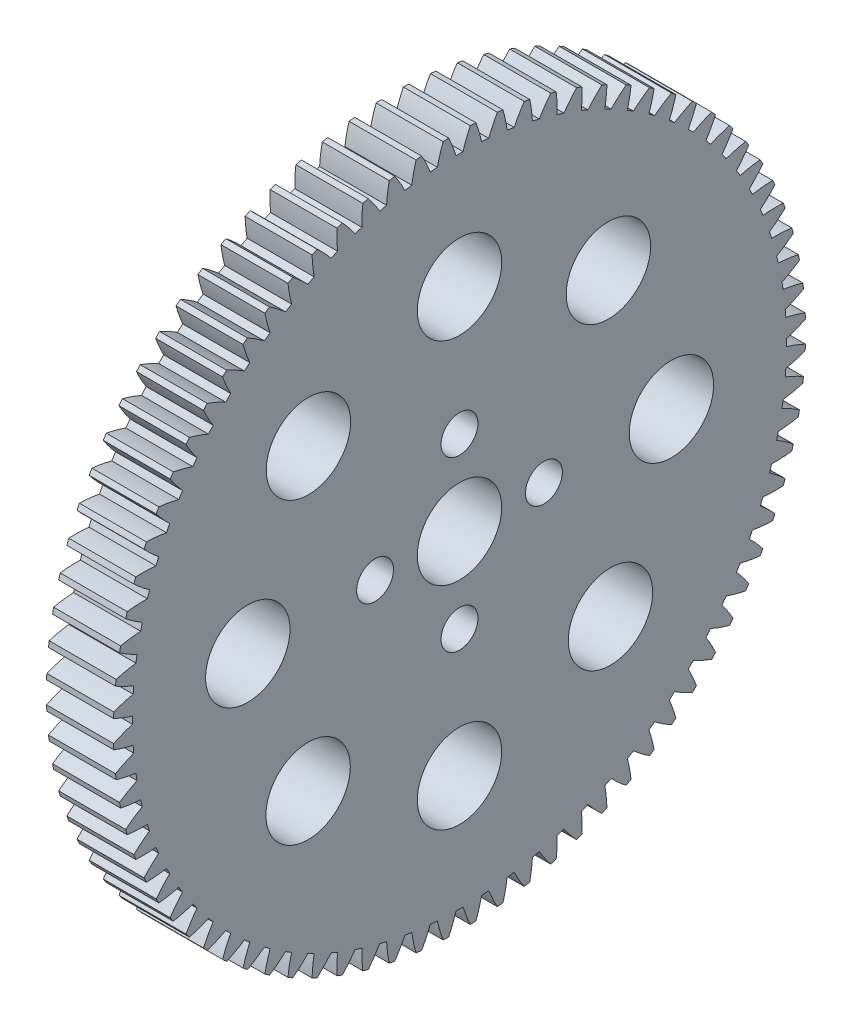
from build123d import *

# Parameters (mm, degrees)
SKETCH1_R           = 4
SKETCH1_R_2         = 1.75
BOSS_EXTRUDE1_DEPTH = 3.175


with BuildPart() as part:
    # Sketch1 → Boss-Extrude1 (new, symmetric)
    with BuildSketch(Plane(origin=(0, 0, 0), x_dir=(0, -1, 0), z_dir=(-1, 0, 0))):
        with BuildLine():
            ThreePointArc((-32.540485036, -4.117867604), (-31.611759802, -4.35271874), (-30.668071435, -4.517454533))
            ThreePointArc((-30.668071435, -4.517454533), (-30.61735087, -4.849311982), (-30.563039402, -5.180600688))
            ThreePointArc((-30.563039402, -5.180600688), (-31.409634214, -5.62888948), (-32.220331407, -6.139238063))
            ThreePointArc((-32.220331407, -6.139238063), (-32.169757197, -6.398962562), (-32.117089412, -6.658270623))
            ThreePointArc((-32.117089412, -6.658270623), (-31.17280092, -6.819530849), (-30.219096608, -6.909717881))
            ThreePointArc((-30.219096608, -6.909717881), (-30.142495162, -7.236572834), (-30.062358507, -7.562579059))
            ThreePointArc((-30.062358507, -7.562579059), (-30.871171216, -8.075908989), (-31.639327812, -8.648290907))
            ThreePointArc((-31.639327812, -8.648290907), (-31.568531756, -8.903246756), (-31.495681252, -9.15762319))
            ThreePointArc((-31.495681252, -9.15762319), (-30.541651355, -9.244298283), (-29.583811002, -9.25938052))
            ThreePointArc((-29.583811002, -9.25938052), (-29.481800949, -9.579217809), (-29.376333174, -9.897931615))
            ThreePointArc((-29.376333174, -9.897931615), (-30.142377181, -10.473137835), (-30.863257239, -11.104024162))
            ThreePointArc((-30.863257239, -11.104024162), (-30.772675818, -11.352639472), (-30.680091743, -11.600515964))
            ThreePointArc((-30.680091743, -11.600515964), (-29.722202353, -11.612071544), (-28.766131363, -11.551955999))
            ThreePointArc((-28.766131363, -11.551955999), (-28.639341628, -11.86280372), (-28.509192978, -12.172260132))
            ThreePointArc((-28.509192978, -12.172260132), (-29.227745368, -12.805796303), (-29.896904422, -13.491297415))
            ThreePointArc((-29.896904422, -13.491297415), (-29.787096101, -13.732039391), (-29.675349267, -13.9718877))
            ThreePointArc((-29.675349267, -13.9718877), (-28.719506089, -13.908252522), (-27.771098959, -13.773309829))
            ThreePointArc((-27.771098959, -13.773309829), (-27.620311243, -14.073251501), (-27.466284128, -14.371542617))
            ThreePointArc((-27.466284128, -14.371542617), (-28.132914785, -15.059502778), (-28.746227248, -15.795392334))
            ThreePointArc((-28.746227248, -15.795392334), (-28.617869032, -16.026776721), (-28.487648394, -16.257118102))
            ThreePointArc((-28.487648394, -16.257118102), (-27.53974452, -16.118684499), (-26.604848494, -15.909746623))
            ThreePointArc((-26.604848494, -15.909746623), (-26.430992455, -16.196933008), (-26.254036502, -16.482219763))
            ThreePointArc((-26.254036502, -16.482219763), (-26.864635428, -17.220362411), (-27.418320024, -18.002103406))
            ThreePointArc((-27.418320024, -18.002103406), (-27.272203284, -18.222703643), (-27.124311696, -18.442117965))
            ThreePointArc((-27.124311696, -18.442117965), (-26.190191269, -18.229739426), (-25.274570292, -17.948094538))
            ThreePointArc((-25.274570292, -17.948094538), (-25.078717809, -18.220755036), (-24.879924011, -18.491278544))
            ThreePointArc((-24.879924011, -18.491278544), (-25.430726659, -19.275052784), (-25.921369739, -20.097825525))
            ThreePointArc((-25.921369739, -20.097825525), (-25.758395333, -20.306281537), (-25.593744596, -20.513416038))
            ThreePointArc((-25.593744596, -20.513416038), (-24.679166779, -20.228401947), (-23.788465959, -19.875786483))
            ThreePointArc((-23.788465959, -19.875786483), (-23.571824528, -20.13224005), (-23.352418516, -20.386332443))
            ThreePointArc((-23.352418516, -20.386332443), (-23.840029005, -21.210906046), (-24.26460559, -22.069637866))
            ThreePointArc((-24.26460559, -22.069637866), (-24.085778309, -22.264664453), (-23.905383551, -22.458242079))
            ThreePointArc((-23.905383551, -22.458242079), (-23.015987019, -22.102349643), (-22.155697823, -21.680937594))
            ThreePointArc((-22.155697823, -21.680937594), (-21.91960311, -21.91960311), (-21.680937594, -22.155697823))
            ThreePointArc((-21.680937594, -22.155697823), (-22.102349643, -23.015987019), (-22.458242079, -23.905383551))
            ThreePointArc((-22.458242079, -23.905383551), (-22.264664453, -24.085778309), (-22.069637866, -24.26460559))
            ThreePointArc((-22.069637866, -24.26460559), (-21.210906046, -23.840029005), (-20.386332443, -23.352418516))
            ThreePointArc((-20.386332443, -23.352418516), (-20.13224005, -23.571824528), (-19.875786483, -23.788465959))
            ThreePointArc((-19.875786483, -23.788465959), (-20.228401947, -24.679166779), (-20.513416038, -25.593744596))
            ThreePointArc((-20.513416038, -25.593744596), (-20.306281537, -25.758395333), (-20.097825525, -25.921369739))
            ThreePointArc((-20.097825525, -25.921369739), (-19.275052784, -25.430726659), (-18.491278544, -24.879924011))
            ThreePointArc((-18.491278544, -24.879924011), (-18.220755036, -25.078717809), (-17.948094538, -25.274570292))
            ThreePointArc((-17.948094538, -25.274570292), (-18.229739426, -26.190191269), (-18.442117965, -27.124311696))
            ThreePointArc((-18.442117965, -27.124311696), (-18.222703643, -27.272203284), (-18.002103406, -27.418320024))
            ThreePointArc((-18.002103406, -27.418320024), (-17.220362411, -26.864635428), (-16.482219763, -26.254036502))
            ThreePointArc((-16.482219763, -26.254036502), (-16.196933008, -26.430992455), (-15.909746623, -26.604848494))
            ThreePointArc((-15.909746623, -26.604848494), (-16.118684499, -27.53974452), (-16.257118102, -28.487648394))
            ThreePointArc((-16.257118102, -28.487648394), (-16.026776721, -28.617869032), (-15.795392334, -28.746227248))
            ThreePointArc((-15.795392334, -28.746227248), (-15.059502778, -28.132914785), (-14.371542617, -27.466284128))
            ThreePointArc((-14.371542617, -27.466284128), (-14.073251501, -27.620311243), (-13.773309829, -27.771098959))
            ThreePointArc((-13.773309829, -27.771098959), (-13.908252522, -28.719506089), (-13.9718877, -29.675349267))
            ThreePointArc((-13.9718877, -29.675349267), (-13.732039391, -29.787096101), (-13.491297415, -29.896904422))
            ThreePointArc((-13.491297415, -29.896904422), (-12.805796303, -29.227745368), (-12.172260132, -28.509192978))
            ThreePointArc((-12.172260132, -28.509192978), (-11.86280372, -28.639341628), (-11.551955999, -28.766131363))
            ThreePointArc((-11.551955999, -28.766131363), (-11.612071544, -29.722202353), (-11.600515964, -30.680091743))
            ThreePointArc((-11.600515964, -30.680091743), (-11.352639472, -30.772675818), (-11.104024162, -30.863257239))
            ThreePointArc((-11.104024162, -30.863257239), (-10.473137835, -30.142377181), (-9.897931615, -29.376333174))
            ThreePointArc((-9.897931615, -29.376333174), (-9.579217809, -29.481800949), (-9.25938052, -29.583811002))
            ThreePointArc((-9.25938052, -29.583811002), (-9.244298283, -30.541651355), (-9.15762319, -31.495681252))
            ThreePointArc((-9.15762319, -31.495681252), (-8.903246756, -31.568531756), (-8.648290907, -31.639327812))
            ThreePointArc((-8.648290907, -31.639327812), (-8.075908989, -30.871171216), (-7.562579059, -30.062358507))
            ThreePointArc((-7.562579059, -30.062358507), (-7.236572834, -30.142495162), (-6.909717881, -30.219096608))
            ThreePointArc((-6.909717881, -30.219096608), (-6.819530849, -31.17280092), (-6.658270623, -32.117089412))
            ThreePointArc((-6.658270623, -32.117089412), (-6.398962562, -32.169757197), (-6.139238063, -32.220331407))
            ThreePointArc((-6.139238063, -32.220331407), (-5.62888948, -31.409634214), (-5.180600688, -30.563039402))
            ThreePointArc((-5.180600688, -30.563039402), (-4.849311982, -30.61735087), (-4.517454533, -30.668071435))
            ThreePointArc((-4.517454533, -30.668071435), (-4.35271874, -31.611759802), (-4.117867604, -32.540485036))
            ThreePointArc((-4.117867604, -32.540485036), (-3.855226637, -32.572645388), (-3.592334775, -32.602685946))
            ThreePointArc((-3.592334775, -32.602685946), (-3.147165994, -31.754446373), (-2.76668219, -30.875288997))
            ThreePointArc((-2.76668219, -30.875288997), (-2.432153508, -30.903440428), (-2.097339576, -30.927967403))
            ThreePointArc((-2.097339576, -30.927967403), (-1.859070673, -31.855821673), (-1.552076562, -32.763257749))
            ThreePointArc((-1.552076562, -32.763257749), (-1.287721957, -32.774712389), (-1.023283548, -32.784034083))
            ThreePointArc((-1.023283548, -32.784034083), (-0.646039184, -31.90348181), (-0.335706178, -30.997182168))
            ThreePointArc((-0.335706178, -30.997182168), (0, -30.999), (0.335706178, -30.997182168))
            ThreePointArc((0.335706178, -30.997182168), (0.646039184, -31.90348181), (1.023283548, -32.784034083))
            ThreePointArc((1.023283548, -32.784034083), (1.287721957, -32.774712389), (1.552076562, -32.763257749))
            ThreePointArc((1.552076562, -32.763257749), (1.859070673, -31.855821673), (2.097339576, -30.927967403))
            ThreePointArc((2.097339576, -30.927967403), (2.432153508, -30.903440428), (2.76668219, -30.875288997))
            ThreePointArc((2.76668219, -30.875288997), (3.147165994, -31.754446373), (3.592334775, -32.602685946))
            ThreePointArc((3.592334775, -32.602685946), (3.855226637, -32.572645388), (4.117867604, -32.540485036))
            ThreePointArc((4.117867604, -32.540485036), (4.35271874, -31.611759802), (4.517454533, -30.668071435))
            ThreePointArc((4.517454533, -30.668071435), (4.849311982, -30.61735087), (5.180600688, -30.563039402))
            ThreePointArc((5.180600688, -30.563039402), (5.62888948, -31.409634214), (6.139238063, -32.220331407))
            ThreePointArc((6.139238063, -32.220331407), (6.398962562, -32.169757197), (6.658270623, -32.117089412))
            ThreePointArc((6.658270623, -32.117089412), (6.819530849, -31.17280092), (6.909717881, -30.219096608))
            ThreePointArc((6.909717881, -30.219096608), (7.236572834, -30.142495162), (7.562579059, -30.062358507))
            ThreePointArc((7.562579059, -30.062358507), (8.075908989, -30.871171216), (8.648290907, -31.639327812))
            ThreePointArc((8.648290907, -31.639327812), (8.903246756, -31.568531756), (9.15762319, -31.495681252))
            ThreePointArc((9.15762319, -31.495681252), (9.244298283, -30.541651355), (9.25938052, -29.583811002))
            ThreePointArc((9.25938052, -29.583811002), (9.579217809, -29.481800949), (9.897931615, -29.376333174))
            ThreePointArc((9.897931615, -29.376333174), (10.473137835, -30.142377181), (11.104024162, -30.863257239))
            ThreePointArc((11.104024162, -30.863257239), (11.352639472, -30.772675818), (11.600515964, -30.680091743))
            ThreePointArc((11.600515964, -30.680091743), (11.612071544, -29.722202353), (11.551955999, -28.766131363))
            ThreePointArc((11.551955999, -28.766131363), (11.86280372, -28.639341628), (12.172260132, -28.509192978))
            ThreePointArc((12.172260132, -28.509192978), (12.805796303, -29.227745368), (13.491297415, -29.896904422))
            ThreePointArc((13.491297415, -29.896904422), (13.732039391, -29.787096101), (13.9718877, -29.675349267))
            ThreePointArc((13.9718877, -29.675349267), (13.908252522, -28.719506089), (13.773309829, -27.771098959))
            ThreePointArc((13.773309829, -27.771098959), (14.073251501, -27.620311243), (14.371542617, -27.466284128))
            ThreePointArc((14.371542617, -27.466284128), (15.059502778, -28.132914785), (15.795392334, -28.746227248))
            ThreePointArc((15.795392334, -28.746227248), (16.026776721, -28.617869032), (16.257118102, -28.487648394))
            ThreePointArc((16.257118102, -28.487648394), (16.118684499, -27.53974452), (15.909746623, -26.604848494))
            ThreePointArc((15.909746623, -26.604848494), (16.196933008, -26.430992455), (16.482219763, -26.254036502))
            ThreePointArc((16.482219763, -26.254036502), (17.220362411, -26.864635428), (18.002103406, -27.418320024))
            ThreePointArc((18.002103406, -27.418320024), (18.222703643, -27.272203284), (18.442117965, -27.124311696))
            ThreePointArc((18.442117965, -27.124311696), (18.229739426, -26.190191269), (17.948094538, -25.274570292))
            ThreePointArc((17.948094538, -25.274570292), (18.220755036, -25.078717809), (18.491278544, -24.879924011))
            ThreePointArc((18.491278544, -24.879924011), (19.275052784, -25.430726659), (20.097825525, -25.921369739))
            ThreePointArc((20.097825525, -25.921369739), (20.306281537, -25.758395333), (20.513416038, -25.593744596))
            ThreePointArc((20.513416038, -25.593744596), (20.228401947, -24.679166779), (19.875786483, -23.788465959))
            ThreePointArc((19.875786483, -23.788465959), (20.13224005, -23.571824528), (20.386332443, -23.352418516))
            ThreePointArc((20.386332443, -23.352418516), (21.210906046, -23.840029005), (22.069637866, -24.26460559))
            ThreePointArc((22.069637866, -24.26460559), (22.264664453, -24.085778309), (22.458242079, -23.905383551))
            ThreePointArc((22.458242079, -23.905383551), (22.102349643, -23.015987019), (21.680937594, -22.155697823))
            ThreePointArc((21.680937594, -22.155697823), (21.91960311, -21.91960311), (22.155697823, -21.680937594))
            ThreePointArc((22.155697823, -21.680937594), (23.015987019, -22.102349643), (23.905383551, -22.458242079))
            ThreePointArc((23.905383551, -22.458242079), (24.085778309, -22.264664453), (24.26460559, -22.069637866))
            ThreePointArc((24.26460559, -22.069637866), (23.840029005, -21.210906046), (23.352418516, -20.386332443))
            ThreePointArc((23.352418516, -20.386332443), (23.571824528, -20.13224005), (23.788465959, -19.875786483))
            ThreePointArc((23.788465959, -19.875786483), (24.679166779, -20.228401947), (25.593744596, -20.513416038))
            ThreePointArc((25.593744596, -20.513416038), (25.758395333, -20.306281537), (25.921369739, -20.097825525))
            ThreePointArc((25.921369739, -20.097825525), (25.430726659, -19.275052784), (24.879924011, -18.491278544))
            ThreePointArc((24.879924011, -18.491278544), (25.078717809, -18.220755036), (25.274570292, -17.948094538))
            ThreePointArc((25.274570292, -17.948094538), (26.190191269, -18.229739426), (27.124311696, -18.442117965))
            ThreePointArc((27.124311696, -18.442117965), (27.272203284, -18.222703643), (27.418320024, -18.002103406))
            ThreePointArc((27.418320024, -18.002103406), (26.864635428, -17.220362411), (26.254036502, -16.482219763))
            ThreePointArc((26.254036502, -16.482219763), (26.430992455, -16.196933008), (26.604848494, -15.909746623))
            ThreePointArc((26.604848494, -15.909746623), (27.53974452, -16.118684499), (28.487648394, -16.257118102))
            ThreePointArc((28.487648394, -16.257118102), (28.617869032, -16.026776721), (28.746227248, -15.795392334))
            ThreePointArc((28.746227248, -15.795392334), (28.132914785, -15.059502778), (27.466284128, -14.371542617))
            ThreePointArc((27.466284128, -14.371542617), (27.620311243, -14.073251501), (27.771098959, -13.773309829))
            ThreePointArc((27.771098959, -13.773309829), (28.719506089, -13.908252522), (29.675349267, -13.9718877))
            ThreePointArc((29.675349267, -13.9718877), (29.787096101, -13.732039391), (29.896904422, -13.491297415))
            ThreePointArc((29.896904422, -13.491297415), (29.227745368, -12.805796303), (28.509192978, -12.172260132))
            ThreePointArc((28.509192978, -12.172260132), (28.639341628, -11.86280372), (28.766131363, -11.551955999))
            ThreePointArc((28.766131363, -11.551955999), (29.722202353, -11.612071544), (30.680091743, -11.600515964))
            ThreePointArc((30.680091743, -11.600515964), (30.772675818, -11.352639472), (30.863257239, -11.104024162))
            ThreePointArc((30.863257239, -11.104024162), (30.142377181, -10.473137835), (29.376333174, -9.897931615))
            ThreePointArc((29.376333174, -9.897931615), (29.481800949, -9.579217809), (29.583811002, -9.25938052))
            ThreePointArc((29.583811002, -9.25938052), (30.541651355, -9.244298283), (31.495681252, -9.15762319))
            ThreePointArc((31.495681252, -9.15762319), (31.568531756, -8.903246756), (31.639327812, -8.648290907))
            ThreePointArc((31.639327812, -8.648290907), (30.871171216, -8.075908989), (30.062358507, -7.562579059))
            ThreePointArc((30.062358507, -7.562579059), (30.142495162, -7.236572834), (30.219096608, -6.909717881))
            ThreePointArc((30.219096608, -6.909717881), (31.17280092, -6.819530849), (32.117089412, -6.658270623))
            ThreePointArc((32.117089412, -6.658270623), (32.169757197, -6.398962562), (32.220331407, -6.139238063))
            ThreePointArc((32.220331407, -6.139238063), (31.409634214, -5.62888948), (30.563039402, -5.180600688))
            ThreePointArc((30.563039402, -5.180600688), (30.61735087, -4.849311982), (30.668071435, -4.517454533))
            ThreePointArc((30.668071435, -4.517454533), (31.611759802, -4.35271874), (32.540485036, -4.117867604))
            ThreePointArc((32.540485036, -4.117867604), (32.572645388, -3.855226637), (32.602685946, -3.592334775))
            ThreePointArc((32.602685946, -3.592334775), (31.754446373, -3.147165994), (30.875288997, -2.76668219))
            ThreePointArc((30.875288997, -2.76668219), (30.903440428, -2.432153508), (30.927967403, -2.097339576))
            ThreePointArc((30.927967403, -2.097339576), (31.855821673, -1.859070673), (32.763257749, -1.552076562))
            ThreePointArc((32.763257749, -1.552076562), (32.774712389, -1.287721957), (32.784034083, -1.023283548))
            ThreePointArc((32.784034083, -1.023283548), (31.90348181, -0.646039184), (30.997182168, -0.335706178))
            ThreePointArc((30.997182168, -0.335706178), (30.999, 0), (30.997182168, 0.335706178))
            ThreePointArc((30.997182168, 0.335706178), (31.90348181, 0.646039184), (32.784034083, 1.023283548))
            ThreePointArc((32.784034083, 1.023283548), (32.774712389, 1.287721957), (32.763257749, 1.552076562))
            ThreePointArc((32.763257749, 1.552076562), (31.855821673, 1.859070673), (30.927967403, 2.097339576))
            ThreePointArc((30.927967403, 2.097339576), (30.903440428, 2.432153508), (30.875288997, 2.76668219))
            ThreePointArc((30.875288997, 2.76668219), (31.754446373, 3.147165994), (32.602685946, 3.592334775))
            ThreePointArc((32.602685946, 3.592334775), (32.572645388, 3.855226637), (32.540485036, 4.117867604))
            ThreePointArc((32.540485036, 4.117867604), (31.611759802, 4.35271874), (30.668071435, 4.517454533))
            ThreePointArc((30.668071435, 4.517454533), (30.61735087, 4.849311982), (30.563039402, 5.180600688))
            ThreePointArc((30.563039402, 5.180600688), (31.409634214, 5.62888948), (32.220331407, 6.139238063))
            ThreePointArc((32.220331407, 6.139238063), (32.169757197, 6.398962562), (32.117089412, 6.658270623))
            ThreePointArc((32.117089412, 6.658270623), (31.17280092, 6.819530849), (30.219096608, 6.909717881))
            ThreePointArc((30.219096608, 6.909717881), (30.142495162, 7.236572834), (30.062358507, 7.562579059))
            ThreePointArc((30.062358507, 7.562579059), (30.871171216, 8.075908989), (31.639327812, 8.648290907))
            ThreePointArc((31.639327812, 8.648290907), (31.568531756, 8.903246756), (31.495681252, 9.15762319))
            ThreePointArc((31.495681252, 9.15762319), (30.541651355, 9.244298283), (29.583811002, 9.25938052))
            ThreePointArc((29.583811002, 9.25938052), (29.481800949, 9.579217809), (29.376333174, 9.897931615))
            ThreePointArc((29.376333174, 9.897931615), (30.142377181, 10.473137835), (30.863257239, 11.104024162))
            ThreePointArc((30.863257239, 11.104024162), (30.772675818, 11.352639472), (30.680091743, 11.600515964))
            ThreePointArc((30.680091743, 11.600515964), (29.722202353, 11.612071544), (28.766131363, 11.551955999))
            ThreePointArc((28.766131363, 11.551955999), (28.639341628, 11.86280372), (28.509192978, 12.172260132))
            ThreePointArc((28.509192978, 12.172260132), (29.227745368, 12.805796303), (29.896904422, 13.491297415))
            ThreePointArc((29.896904422, 13.491297415), (29.787096101, 13.732039391), (29.675349267, 13.9718877))
            ThreePointArc((29.675349267, 13.9718877), (28.719506089, 13.908252522), (27.771098959, 13.773309829))
            ThreePointArc((27.771098959, 13.773309829), (27.620311243, 14.073251501), (27.466284128, 14.371542617))
            ThreePointArc((27.466284128, 14.371542617), (28.132914785, 15.059502778), (28.746227248, 15.795392334))
            ThreePointArc((28.746227248, 15.795392334), (28.617869032, 16.026776721), (28.487648394, 16.257118102))
            ThreePointArc((28.487648394, 16.257118102), (27.53974452, 16.118684499), (26.604848494, 15.909746623))
            ThreePointArc((26.604848494, 15.909746623), (26.430992455, 16.196933008), (26.254036502, 16.482219763))
            ThreePointArc((26.254036502, 16.482219763), (26.864635428, 17.220362411), (27.418320024, 18.002103406))
            ThreePointArc((27.418320024, 18.002103406), (27.272203284, 18.222703643), (27.124311696, 18.442117965))
            ThreePointArc((27.124311696, 18.442117965), (26.190191269, 18.229739426), (25.274570292, 17.948094538))
            ThreePointArc((25.274570292, 17.948094538), (25.078717809, 18.220755036), (24.879924011, 18.491278544))
            ThreePointArc((24.879924011, 18.491278544), (25.430726659, 19.275052784), (25.921369739, 20.097825525))
            ThreePointArc((25.921369739, 20.097825525), (25.758395333, 20.306281537), (25.593744596, 20.513416038))
            ThreePointArc((25.593744596, 20.513416038), (24.679166779, 20.228401947), (23.788465959, 19.875786483))
            ThreePointArc((23.788465959, 19.875786483), (23.571824528, 20.13224005), (23.352418516, 20.386332443))
            ThreePointArc((23.352418516, 20.386332443), (23.840029005, 21.210906046), (24.26460559, 22.069637866))
            ThreePointArc((24.26460559, 22.069637866), (24.085778309, 22.264664453), (23.905383551, 22.458242079))
            ThreePointArc((23.905383551, 22.458242079), (23.015987019, 22.102349643), (22.155697823, 21.680937594))
            ThreePointArc((22.155697823, 21.680937594), (21.91960311, 21.91960311), (21.680937594, 22.155697823))
            ThreePointArc((21.680937594, 22.155697823), (22.102349643, 23.015987019), (22.458242079, 23.905383551))
            ThreePointArc((22.458242079, 23.905383551), (22.264664453, 24.085778309), (22.069637866, 24.26460559))
            ThreePointArc((22.069637866, 24.26460559), (21.210906046, 23.840029005), (20.386332443, 23.352418516))
            ThreePointArc((20.386332443, 23.352418516), (20.13224005, 23.571824528), (19.875786483, 23.788465959))
            ThreePointArc((19.875786483, 23.788465959), (20.228401947, 24.679166779), (20.513416038, 25.593744596))
            ThreePointArc((20.513416038, 25.593744596), (20.306281537, 25.758395333), (20.097825525, 25.921369739))
            ThreePointArc((20.097825525, 25.921369739), (19.275052784, 25.430726659), (18.491278544, 24.879924011))
            ThreePointArc((18.491278544, 24.879924011), (18.220755036, 25.078717809), (17.948094538, 25.274570292))
            ThreePointArc((17.948094538, 25.274570292), (18.229739426, 26.190191269), (18.442117965, 27.124311696))
            ThreePointArc((18.442117965, 27.124311696), (18.222703643, 27.272203284), (18.002103406, 27.418320024))
            ThreePointArc((18.002103406, 27.418320024), (17.220362411, 26.864635428), (16.482219763, 26.254036502))
            ThreePointArc((16.482219763, 26.254036502), (16.196933008, 26.430992455), (15.909746623, 26.604848494))
            ThreePointArc((15.909746623, 26.604848494), (16.118684499, 27.53974452), (16.257118102, 28.487648394))
            ThreePointArc((16.257118102, 28.487648394), (16.026776721, 28.617869032), (15.795392334, 28.746227248))
            ThreePointArc((15.795392334, 28.746227248), (15.059502778, 28.132914785), (14.371542617, 27.466284128))
            ThreePointArc((14.371542617, 27.466284128), (14.073251501, 27.620311243), (13.773309829, 27.771098959))
            ThreePointArc((13.773309829, 27.771098959), (13.908252522, 28.719506089), (13.9718877, 29.675349267))
            ThreePointArc((13.9718877, 29.675349267), (13.732039391, 29.787096101), (13.491297415, 29.896904422))
            ThreePointArc((13.491297415, 29.896904422), (12.805796303, 29.227745368), (12.172260132, 28.509192978))
            ThreePointArc((12.172260132, 28.509192978), (11.86280372, 28.639341628), (11.551955999, 28.766131363))
            ThreePointArc((11.551955999, 28.766131363), (11.612071544, 29.722202353), (11.600515964, 30.680091743))
            ThreePointArc((11.600515964, 30.680091743), (11.352639472, 30.772675818), (11.104024162, 30.863257239))
            ThreePointArc((11.104024162, 30.863257239), (10.473137835, 30.142377181), (9.897931615, 29.376333174))
            ThreePointArc((9.897931615, 29.376333174), (9.579217809, 29.481800949), (9.25938052, 29.583811002))
            ThreePointArc((9.25938052, 29.583811002), (9.244298283, 30.541651355), (9.15762319, 31.495681252))
            ThreePointArc((9.15762319, 31.495681252), (8.903246756, 31.568531756), (8.648290907, 31.639327812))
            ThreePointArc((8.648290907, 31.639327812), (8.075908989, 30.871171216), (7.562579059, 30.062358507))
            ThreePointArc((7.562579059, 30.062358507), (7.236572834, 30.142495162), (6.909717881, 30.219096608))
            ThreePointArc((6.909717881, 30.219096608), (6.819530849, 31.17280092), (6.658270623, 32.117089412))
            ThreePointArc((6.658270623, 32.117089412), (6.398962562, 32.169757197), (6.139238063, 32.220331407))
            ThreePointArc((6.139238063, 32.220331407), (5.62888948, 31.409634214), (5.180600688, 30.563039402))
            ThreePointArc((5.180600688, 30.563039402), (4.849311982, 30.61735087), (4.517454533, 30.668071435))
            ThreePointArc((4.517454533, 30.668071435), (4.35271874, 31.611759802), (4.117867604, 32.540485036))
            ThreePointArc((4.117867604, 32.540485036), (3.855226637, 32.572645388), (3.592334775, 32.602685946))
            ThreePointArc((3.592334775, 32.602685946), (3.147165994, 31.754446373), (2.76668219, 30.875288997))
            ThreePointArc((2.76668219, 30.875288997), (2.432153508, 30.903440428), (2.097339576, 30.927967403))
            ThreePointArc((2.097339576, 30.927967403), (1.859070673, 31.855821673), (1.552076562, 32.763257749))
            ThreePointArc((1.552076562, 32.763257749), (1.287721957, 32.774712389), (1.023283548, 32.784034083))
            ThreePointArc((1.023283548, 32.784034083), (0.646039184, 31.90348181), (0.335706178, 30.997182168))
            ThreePointArc((0.335706178, 30.997182168), (0, 30.999), (-0.335706178, 30.997182168))
            ThreePointArc((-0.335706178, 30.997182168), (-0.646039184, 31.90348181), (-1.023283548, 32.784034083))
            ThreePointArc((-1.023283548, 32.784034083), (-1.287721957, 32.774712389), (-1.552076562, 32.763257749))
            ThreePointArc((-1.552076562, 32.763257749), (-1.859070673, 31.855821673), (-2.097339576, 30.927967403))
            ThreePointArc((-2.097339576, 30.927967403), (-2.432153508, 30.903440428), (-2.76668219, 30.875288997))
            ThreePointArc((-2.76668219, 30.875288997), (-3.147165994, 31.754446373), (-3.592334775, 32.602685946))
            ThreePointArc((-3.592334775, 32.602685946), (-3.855226637, 32.572645388), (-4.117867604, 32.540485036))
            ThreePointArc((-4.117867604, 32.540485036), (-4.35271874, 31.611759802), (-4.517454533, 30.668071435))
            ThreePointArc((-4.517454533, 30.668071435), (-4.849311982, 30.61735087), (-5.180600688, 30.563039402))
            ThreePointArc((-5.180600688, 30.563039402), (-5.62888948, 31.409634214), (-6.139238063, 32.220331407))
            ThreePointArc((-6.139238063, 32.220331407), (-6.398962562, 32.169757197), (-6.658270623, 32.117089412))
            ThreePointArc((-6.658270623, 32.117089412), (-6.819530849, 31.17280092), (-6.909717881, 30.219096608))
            ThreePointArc((-6.909717881, 30.219096608), (-7.236572834, 30.142495162), (-7.562579059, 30.062358507))
            ThreePointArc((-7.562579059, 30.062358507), (-8.075908989, 30.871171216), (-8.648290907, 31.639327812))
            ThreePointArc((-8.648290907, 31.639327812), (-8.903246756, 31.568531756), (-9.15762319, 31.495681252))
            ThreePointArc((-9.15762319, 31.495681252), (-9.244298283, 30.541651355), (-9.25938052, 29.583811002))
            ThreePointArc((-9.25938052, 29.583811002), (-9.579217809, 29.481800949), (-9.897931615, 29.376333174))
            ThreePointArc((-9.897931615, 29.376333174), (-10.473137835, 30.142377181), (-11.104024162, 30.863257239))
            ThreePointArc((-11.104024162, 30.863257239), (-11.352639472, 30.772675818), (-11.600515964, 30.680091743))
            ThreePointArc((-11.600515964, 30.680091743), (-11.612071544, 29.722202353), (-11.551955999, 28.766131363))
            ThreePointArc((-11.551955999, 28.766131363), (-11.86280372, 28.639341628), (-12.172260132, 28.509192978))
            ThreePointArc((-12.172260132, 28.509192978), (-12.805796303, 29.227745368), (-13.491297415, 29.896904422))
            ThreePointArc((-13.491297415, 29.896904422), (-13.732039391, 29.787096101), (-13.9718877, 29.675349267))
            ThreePointArc((-13.9718877, 29.675349267), (-13.908252522, 28.719506089), (-13.773309829, 27.771098959))
            ThreePointArc((-13.773309829, 27.771098959), (-14.073251501, 27.620311243), (-14.371542617, 27.466284128))
            ThreePointArc((-14.371542617, 27.466284128), (-15.059502778, 28.132914785), (-15.795392334, 28.746227248))
            ThreePointArc((-15.795392334, 28.746227248), (-16.026776721, 28.617869032), (-16.257118102, 28.487648394))
            ThreePointArc((-16.257118102, 28.487648394), (-16.118684499, 27.53974452), (-15.909746623, 26.604848494))
            ThreePointArc((-15.909746623, 26.604848494), (-16.196933008, 26.430992455), (-16.482219763, 26.254036502))
            ThreePointArc((-16.482219763, 26.254036502), (-17.220362411, 26.864635428), (-18.002103406, 27.418320024))
            ThreePointArc((-18.002103406, 27.418320024), (-18.222703643, 27.272203284), (-18.442117965, 27.124311696))
            ThreePointArc((-18.442117965, 27.124311696), (-18.229739426, 26.190191269), (-17.948094538, 25.274570292))
            ThreePointArc((-17.948094538, 25.274570292), (-18.220755036, 25.078717809), (-18.491278544, 24.879924011))
            ThreePointArc((-18.491278544, 24.879924011), (-19.275052784, 25.430726659), (-20.097825525, 25.921369739))
            ThreePointArc((-20.097825525, 25.921369739), (-20.306281537, 25.758395333), (-20.513416038, 25.593744596))
            ThreePointArc((-20.513416038, 25.593744596), (-20.228401947, 24.679166779), (-19.875786483, 23.788465959))
            ThreePointArc((-19.875786483, 23.788465959), (-20.13224005, 23.571824528), (-20.386332443, 23.352418516))
            ThreePointArc((-20.386332443, 23.352418516), (-21.210906046, 23.840029005), (-22.069637866, 24.26460559))
            ThreePointArc((-22.069637866, 24.26460559), (-22.264664453, 24.085778309), (-22.458242079, 23.905383551))
            ThreePointArc((-22.458242079, 23.905383551), (-22.102349643, 23.015987019), (-21.680937594, 22.155697823))
            ThreePointArc((-21.680937594, 22.155697823), (-21.91960311, 21.91960311), (-22.155697823, 21.680937594))
            ThreePointArc((-22.155697823, 21.680937594), (-23.015987019, 22.102349643), (-23.905383551, 22.458242079))
            ThreePointArc((-23.905383551, 22.458242079), (-24.085778309, 22.264664453), (-24.26460559, 22.069637866))
            ThreePointArc((-24.26460559, 22.069637866), (-23.840029005, 21.210906046), (-23.352418516, 20.386332443))
            ThreePointArc((-23.352418516, 20.386332443), (-23.571824528, 20.13224005), (-23.788465959, 19.875786483))
            ThreePointArc((-23.788465959, 19.875786483), (-24.679166779, 20.228401947), (-25.593744596, 20.513416038))
            ThreePointArc((-25.593744596, 20.513416038), (-25.758395333, 20.306281537), (-25.921369739, 20.097825525))
            ThreePointArc((-25.921369739, 20.097825525), (-25.430726659, 19.275052784), (-24.879924011, 18.491278544))
            ThreePointArc((-24.879924011, 18.491278544), (-25.078717809, 18.220755036), (-25.274570292, 17.948094538))
            ThreePointArc((-25.274570292, 17.948094538), (-26.190191269, 18.229739426), (-27.124311696, 18.442117965))
            ThreePointArc((-27.124311696, 18.442117965), (-27.272203284, 18.222703643), (-27.418320024, 18.002103406))
            ThreePointArc((-27.418320024, 18.002103406), (-26.864635428, 17.220362411), (-26.254036502, 16.482219763))
            ThreePointArc((-26.254036502, 16.482219763), (-26.430992455, 16.196933008), (-26.604848494, 15.909746623))
            ThreePointArc((-26.604848494, 15.909746623), (-27.53974452, 16.118684499), (-28.487648394, 16.257118102))
            ThreePointArc((-28.487648394, 16.257118102), (-28.617869032, 16.026776721), (-28.746227248, 15.795392334))
            ThreePointArc((-28.746227248, 15.795392334), (-28.132914785, 15.059502778), (-27.466284128, 14.371542617))
            ThreePointArc((-27.466284128, 14.371542617), (-27.620311243, 14.073251501), (-27.771098959, 13.773309829))
            ThreePointArc((-27.771098959, 13.773309829), (-28.719506089, 13.908252522), (-29.675349267, 13.9718877))
            ThreePointArc((-29.675349267, 13.9718877), (-29.787096101, 13.732039391), (-29.896904422, 13.491297415))
            ThreePointArc((-29.896904422, 13.491297415), (-29.227745368, 12.805796303), (-28.509192978, 12.172260132))
            ThreePointArc((-28.509192978, 12.172260132), (-28.639341628, 11.86280372), (-28.766131363, 11.551955999))
            ThreePointArc((-28.766131363, 11.551955999), (-29.722202353, 11.612071544), (-30.680091743, 11.600515964))
            ThreePointArc((-30.680091743, 11.600515964), (-30.772675818, 11.352639472), (-30.863257239, 11.104024162))
            ThreePointArc((-30.863257239, 11.104024162), (-30.142377181, 10.473137835), (-29.376333174, 9.897931615))
            ThreePointArc((-29.376333174, 9.897931615), (-29.481800949, 9.579217809), (-29.583811002, 9.25938052))
            ThreePointArc((-29.583811002, 9.25938052), (-30.541651355, 9.244298283), (-31.495681252, 9.15762319))
            ThreePointArc((-31.495681252, 9.15762319), (-31.568531756, 8.903246756), (-31.639327812, 8.648290907))
            ThreePointArc((-31.639327812, 8.648290907), (-30.871171216, 8.075908989), (-30.062358507, 7.562579059))
            ThreePointArc((-30.062358507, 7.562579059), (-30.142495162, 7.236572834), (-30.219096608, 6.909717881))
            ThreePointArc((-30.219096608, 6.909717881), (-31.17280092, 6.819530849), (-32.117089412, 6.658270623))
            ThreePointArc((-32.117089412, 6.658270623), (-32.169757197, 6.398962562), (-32.220331407, 6.139238063))
            ThreePointArc((-32.220331407, 6.139238063), (-31.409634214, 5.62888948), (-30.563039402, 5.180600688))
            ThreePointArc((-30.563039402, 5.180600688), (-30.61735087, 4.849311982), (-30.668071435, 4.517454533))
            ThreePointArc((-30.668071435, 4.517454533), (-31.611759802, 4.35271874), (-32.540485036, 4.117867604))
            ThreePointArc((-32.540485036, 4.117867604), (-32.572645388, 3.855226637), (-32.602685946, 3.592334775))
            ThreePointArc((-32.602685946, 3.592334775), (-31.754446373, 3.147165994), (-30.875288997, 2.76668219))
            ThreePointArc((-30.875288997, 2.76668219), (-30.903440428, 2.432153508), (-30.927967403, 2.097339576))
            ThreePointArc((-30.927967403, 2.097339576), (-31.855821673, 1.859070673), (-32.763257749, 1.552076562))
            ThreePointArc((-32.763257749, 1.552076562), (-32.774712389, 1.287721957), (-32.784034083, 1.023283548))
            ThreePointArc((-32.784034083, 1.023283548), (-31.90348181, 0.646039184), (-30.997182168, 0.335706178))
            ThreePointArc((-30.997182168, 0.335706178), (-30.999, 0), (-30.997182168, -0.335706178))
            ThreePointArc((-30.997182168, -0.335706178), (-31.90348181, -0.646039184), (-32.784034083, -1.023283548))
            ThreePointArc((-32.784034083, -1.023283548), (-32.774712389, -1.287721957), (-32.763257749, -1.552076562))
            ThreePointArc((-32.763257749, -1.552076562), (-31.855821673, -1.859070673), (-30.927967403, -2.097339576))
            ThreePointArc((-30.927967403, -2.097339576), (-30.903440428, -2.432153508), (-30.875288997, -2.76668219))
            ThreePointArc((-30.875288997, -2.76668219), (-31.754446373, -3.147165994), (-32.602685946, -3.592334775))
            ThreePointArc((-32.602685946, -3.592334775), (-32.572645388, -3.855226637), (-32.540485036, -4.117867604))
        make_face()
        Circle(SKETCH1_R, mode=Mode.SUBTRACT)
        with Locations((0, 8)):
            Circle(SKETCH1_R_2, mode=Mode.SUBTRACT)
        with Locations((-20.084034083, 0)):
            Circle(SKETCH1_R, mode=Mode.SUBTRACT)
        with Locations((20.063257749, 0)):
            Circle(SKETCH1_R, mode=Mode.SUBTRACT)
        with Locations((0, -20.084034083)):
            Circle(SKETCH1_R, mode=Mode.SUBTRACT)
        with Locations((0, 20.063257749)):
            Circle(SKETCH1_R, mode=Mode.SUBTRACT)
        with Locations((-14.36634376, -14.112602443)):
            Circle(SKETCH1_R, mode=Mode.SUBTRACT)
        with Locations((14.14202094, -14.306921905)):
            Circle(SKETCH1_R, mode=Mode.SUBTRACT)
        with Locations((14.135100494, 14.348299993)):
            Circle(SKETCH1_R, mode=Mode.SUBTRACT)
        with Locations((-14.159703758, 14.315040904)):
            Circle(SKETCH1_R, mode=Mode.SUBTRACT)
        with Locations((-8, 0)):
            Circle(SKETCH1_R_2, mode=Mode.SUBTRACT)
        with Locations((8, 0)):
            Circle(SKETCH1_R_2, mode=Mode.SUBTRACT)
        with Locations((0, -8)):
            Circle(SKETCH1_R_2, mode=Mode.SUBTRACT)
    extrude(amount=BOSS_EXTRUDE1_DEPTH, both=True)


solid = part.part
